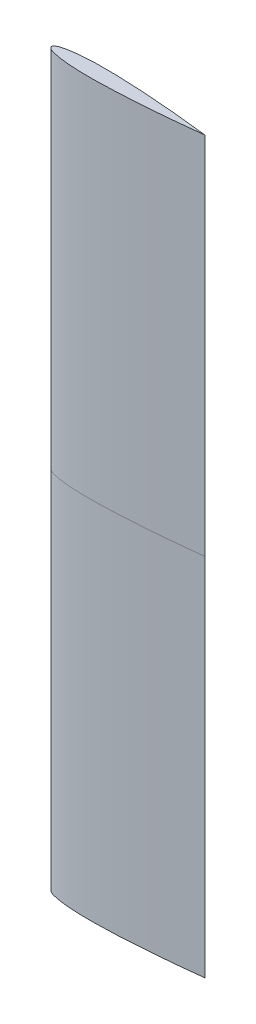
from build123d import *


with BuildPart() as part:
    # rootSketch → Loft1 section 0
    with BuildSketch(Plane(origin=(0, 0, 0), x_dir=(1, 0, 0), z_dir=(0, 1, 0))):
        with BuildLine():
            add(Edge.make_bspline(
                [(0, 0), (0.000103465, 0.195763512), (0.028293768, 0.492759489), (0.127222576, 0.894156677), (0.343186549, 1.378514144), (0.594318401, 1.793627367), (0.950055747, 2.249921566), (1.471381731, 2.779826786), (2.279282722, 3.431035429), (3.60301809, 4.268673485), (5.870802561, 5.366944641), (9.930055947, 6.81744903), (17.152236409, 8.612219673), (28.720275122, 10.447874485), (44.168465096, 11.820627537), (62.542432795, 12.528318105), (82.333782025, 12.56846888), (99.644964653, 12.153826081), (114.474754262, 11.558167514), (126.826489093, 10.929316364), (136.704306809, 10.355663872), (146.57766272, 9.719006975), (156.448177875, 9.024977187), (166.313103966, 8.27853177), (176.177102826, 7.48246039), (186.032159331, 6.640021129), (194.659964932, 5.861869827), (202.039567165, 5.168037507), (208.208074404, 4.568176906), (213.104800748, 4.081126664), (218.075005881, 3.57319926), (222.911526959, 3.069232059), (227.970719553, 2.525750208), (232.656068057, 2.014643232), (237.95637907, 1.415725392), (242.23323243, 0.926982629), (246.711229679, 0.395821131), (248.883194299, 0.135273091), (250, 0)],
                knots=[0, 0, 0, 0, 0, 0.0027914, 0.004280534, 0.005882719, 0.007585099, 0.009734657, 0.012561595, 0.016522403, 0.022438151, 0.032158027, 0.04863424, 0.078248652, 0.129036717, 0.199997011, 0.270957307, 0.341917602, 0.412877898, 0.448358046, 0.483838194, 0.519318343, 0.554798491, 0.590278639, 0.625758787, 0.661238935, 0.696719083, 0.732199231, 0.749939305, 0.767679379, 0.785419453, 0.803159527, 0.820899601, 0.838639675, 0.85637975, 0.874119824, 0.891859898, 0.909599973, 0.909599973, 0.909599973, 0.909599973, 0.909599973], degree=4))
            add(Edge.make_bspline(
                [(0, 0), (0.000103465, -0.195763512), (0.028293768, -0.492759489), (0.127222576, -0.894156677), (0.343186549, -1.378514144), (0.594318401, -1.793627367), (0.950055747, -2.249921566), (1.471381731, -2.779826786), (2.279282722, -3.431035429), (3.60301809, -4.268673485), (5.870802561, -5.366944641), (9.930055947, -6.81744903), (17.152236409, -8.612219673), (28.720275122, -10.447874485), (44.168465096, -11.820627537), (62.542432795, -12.528318105), (82.333782025, -12.56846888), (99.644964653, -12.153826081), (114.474754262, -11.558167514), (126.826489093, -10.929316364), (136.704306809, -10.355663872), (146.57766272, -9.719006975), (156.448177875, -9.024977187), (166.313103966, -8.27853177), (176.177102826, -7.48246039), (186.032159331, -6.640021129), (194.659964932, -5.861869827), (202.039567165, -5.168037507), (208.208074404, -4.568176906), (213.104800748, -4.081126664), (218.075005881, -3.57319926), (222.911526959, -3.069232059), (227.970719553, -2.525750208), (232.656068057, -2.014643232), (237.95637907, -1.415725392), (242.23323243, -0.926982629), (246.711229679, -0.395821131), (248.883194299, -0.135273091), (250, 0)],
                knots=[0, 0, 0, 0, 0, 0.0027914, 0.004280534, 0.005882719, 0.007585099, 0.009734657, 0.012561595, 0.016522403, 0.022438151, 0.032158027, 0.04863424, 0.078248652, 0.129036717, 0.199997011, 0.270957307, 0.341917602, 0.412877898, 0.448358046, 0.483838194, 0.519318343, 0.554798491, 0.590278639, 0.625758787, 0.661238935, 0.696719083, 0.732199231, 0.749939305, 0.767679379, 0.785419453, 0.803159527, 0.820899601, 0.838639675, 0.85637975, 0.874119824, 0.891859898, 0.909599973, 0.909599973, 0.909599973, 0.909599973, 0.909599973], degree=4))
        make_face()
    # tipSketch → Loft1 section 1
    with BuildSketch(Plane(origin=(0, 594, 0), x_dir=(1, 0, 0), z_dir=(0, 1, 0))):
        with BuildLine():
            add(Edge.make_bspline(
                [(0, 0), (0.000103465, 0.195763512), (0.028293768, 0.492759489), (0.127222576, 0.894156677), (0.343186549, 1.378514144), (0.594318401, 1.793627367), (0.950055747, 2.249921566), (1.471381731, 2.779826786), (2.279282722, 3.431035429), (3.60301809, 4.268673485), (5.870802561, 5.366944641), (9.930055947, 6.81744903), (17.152236409, 8.612219673), (28.720275122, 10.447874485), (44.168465096, 11.820627537), (62.542432795, 12.528318105), (82.333782025, 12.56846888), (99.644964653, 12.153826081), (114.474754262, 11.558167514), (126.826489093, 10.929316364), (136.704306809, 10.355663872), (146.57766272, 9.719006975), (156.448177875, 9.024977187), (166.313103966, 8.27853177), (176.177102826, 7.48246039), (186.032159331, 6.640021129), (194.659964932, 5.861869827), (202.039567165, 5.168037507), (208.208074404, 4.568176906), (213.104800748, 4.081126664), (218.075005881, 3.57319926), (222.911526959, 3.069232059), (227.970719553, 2.525750208), (232.656068057, 2.014643232), (237.95637907, 1.415725392), (242.23323243, 0.926982629), (246.711229679, 0.395821131), (248.883194299, 0.135273091), (250, 0)],
                knots=[0, 0, 0, 0, 0, 0.0027914, 0.004280534, 0.005882719, 0.007585099, 0.009734657, 0.012561595, 0.016522403, 0.022438151, 0.032158027, 0.04863424, 0.078248652, 0.129036717, 0.199997011, 0.270957307, 0.341917602, 0.412877898, 0.448358046, 0.483838194, 0.519318343, 0.554798491, 0.590278639, 0.625758787, 0.661238935, 0.696719083, 0.732199231, 0.749939305, 0.767679379, 0.785419453, 0.803159527, 0.820899601, 0.838639675, 0.85637975, 0.874119824, 0.891859898, 0.909599973, 0.909599973, 0.909599973, 0.909599973, 0.909599973], degree=4))
            add(Edge.make_bspline(
                [(0, 0), (0.000103465, -0.195763512), (0.028293768, -0.492759489), (0.127222576, -0.894156677), (0.343186549, -1.378514144), (0.594318401, -1.793627367), (0.950055747, -2.249921566), (1.471381731, -2.779826786), (2.279282722, -3.431035429), (3.60301809, -4.268673485), (5.870802561, -5.366944641), (9.930055947, -6.81744903), (17.152236409, -8.612219673), (28.720275122, -10.447874485), (44.168465096, -11.820627537), (62.542432795, -12.528318105), (82.333782025, -12.56846888), (99.644964653, -12.153826081), (114.474754262, -11.558167514), (126.826489093, -10.929316364), (136.704306809, -10.355663872), (146.57766272, -9.719006975), (156.448177875, -9.024977187), (166.313103966, -8.27853177), (176.177102826, -7.48246039), (186.032159331, -6.640021129), (194.659964932, -5.861869827), (202.039567165, -5.168037507), (208.208074404, -4.568176906), (213.104800748, -4.081126664), (218.075005881, -3.57319926), (222.911526959, -3.069232059), (227.970719553, -2.525750208), (232.656068057, -2.014643232), (237.95637907, -1.415725392), (242.23323243, -0.926982629), (246.711229679, -0.395821131), (248.883194299, -0.135273091), (250, 0)],
                knots=[0, 0, 0, 0, 0, 0.0027914, 0.004280534, 0.005882719, 0.007585099, 0.009734657, 0.012561595, 0.016522403, 0.022438151, 0.032158027, 0.04863424, 0.078248652, 0.129036717, 0.199997011, 0.270957307, 0.341917602, 0.412877898, 0.448358046, 0.483838194, 0.519318343, 0.554798491, 0.590278639, 0.625758787, 0.661238935, 0.696719083, 0.732199231, 0.749939305, 0.767679379, 0.785419453, 0.803159527, 0.820899601, 0.838639675, 0.85637975, 0.874119824, 0.891859898, 0.909599973, 0.909599973, 0.909599973, 0.909599973, 0.909599973], degree=4))
        make_face()
    loft1 = loft()

    # Mirror1: Loft1 across plane
    add(loft1.mirror(Plane.ZX))


solid = part.part
